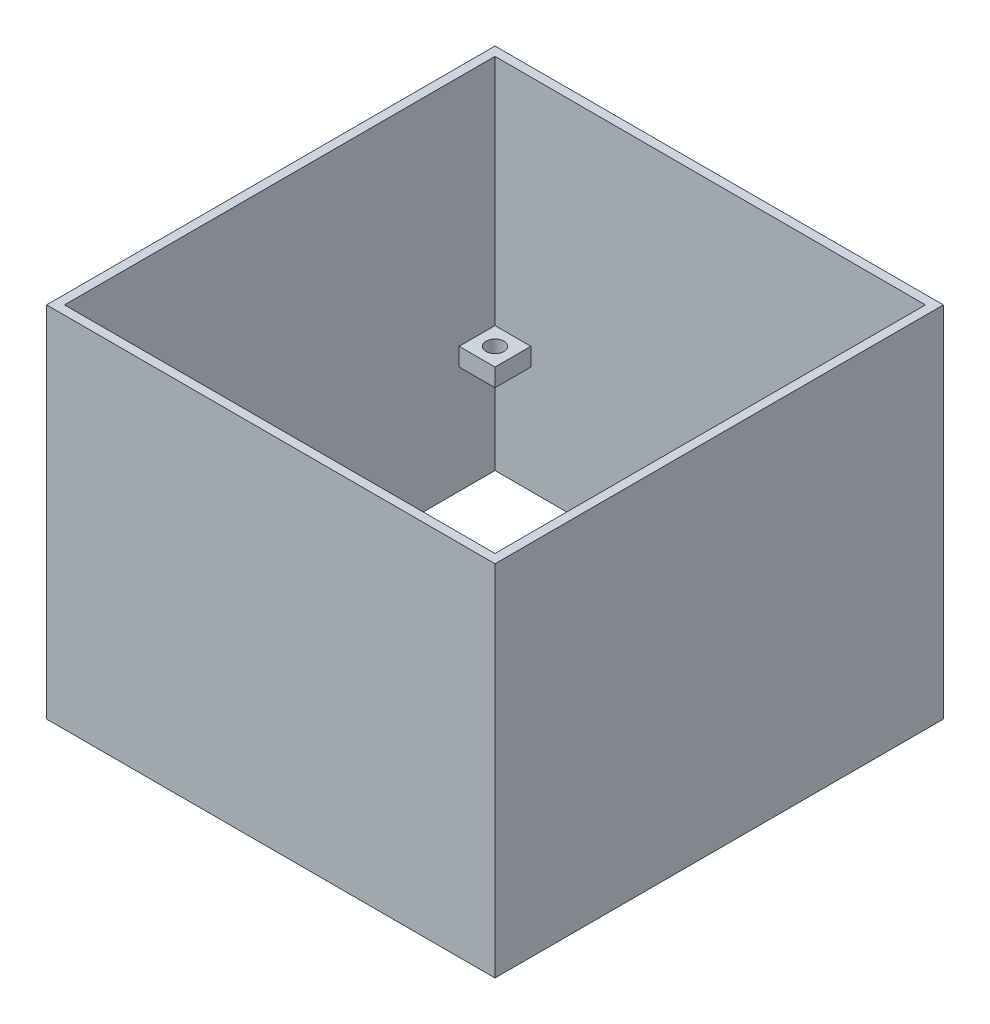
from build123d import *

# Parameters (mm, degrees)
SKETCH1_W           = 125
SKETCH1_H           = 125
SKETCH1_W_2         = 120
SKETCH1_H_2         = 120
BOSS_EXTRUDE1_DEPTH = 100
SKETCH3_W           = 10
SKETCH3_H           = 10
BOSS_EXTRUDE2_DEPTH = 70
SKETCH4_R           = 2.5
CUT_EXTRUDE1_DEPTH  = 5
SKETCH5_W           = 120
SKETCH5_H           = 120
CUT_EXTRUDE2_DEPTH  = 65


with BuildPart() as part:
    # Sketch1 → Boss-Extrude1 (new body)
    with BuildSketch(Plane(origin=(0, 0, 0), x_dir=(1, 0, 0), z_dir=(0, 1, 0))):
        Rectangle(SKETCH1_W, SKETCH1_H)
        Rectangle(SKETCH1_W_2, SKETCH1_H_2, mode=Mode.SUBTRACT)
    extrude(amount=BOSS_EXTRUDE1_DEPTH)

    # Sketch3 → Boss-Extrude2 (add)
    with BuildSketch(Plane(origin=(0, 100, 0), x_dir=(1, 0, 0), z_dir=(0, 1, 0))):
        with Locations((55, 55)):
            Rectangle(SKETCH3_W, SKETCH3_H)
        with Locations((-55, 55)):
            Rectangle(SKETCH3_W, SKETCH3_H)
        with Locations((55, -55)):
            Rectangle(SKETCH3_W, SKETCH3_H)
        with Locations((-55, -55)):
            Rectangle(SKETCH3_W, SKETCH3_H)
    extrude(amount=-BOSS_EXTRUDE2_DEPTH)

    # Sketch4 → Cut-Extrude1 (cut)
    with BuildSketch(Plane.XZ.offset(-30)):
        with Locations((-55, 55)):
            Circle(SKETCH4_R)
        with Locations((55, 55)):
            Circle(SKETCH4_R)
        with Locations((55, -55)):
            Circle(SKETCH4_R)
        with Locations((-55, -55)):
            Circle(SKETCH4_R)
    extrude(amount=-CUT_EXTRUDE1_DEPTH, mode=Mode.SUBTRACT)

    # Sketch5 → Cut-Extrude2 (cut)
    with BuildSketch(Plane(origin=(0, 100, 0), x_dir=(1, 0, 0), z_dir=(0, 1, 0))):
        Rectangle(SKETCH5_W, SKETCH5_H)
    extrude(amount=-CUT_EXTRUDE2_DEPTH, mode=Mode.SUBTRACT)


solid = part.part
